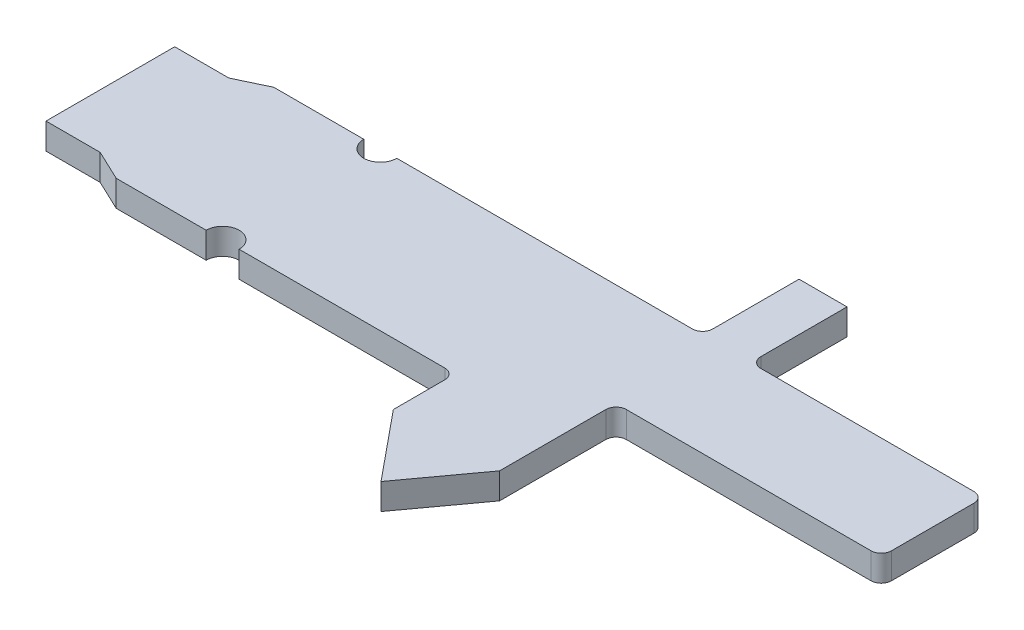
from build123d import *

# Parameters (mm, degrees)
BOSS_EXTRUDE1_DEPTH = 0.9652


with BuildPart() as part:
    # Sketch2 → Boss-Extrude1 (new body)
    with BuildSketch(Plane(origin=(0, 0, 0), x_dir=(1, 0, 0), z_dir=(0, 1, 0))):
        with BuildLine():
            Line((14.732, -0.508), (14.732, 2.54))
            ThreePointArc((14.732, 2.54), (14.620407684, 2.809407684), (14.351, 2.921))
            Line((14.351, 2.921), (6.458532376, 2.921))
            ThreePointArc((6.458532376, 2.921), (6.189124692, 3.032592316), (6.077532376, 3.302))
            Line((6.077532376, 3.302), (6.077532376, 6.495707179))
            Line((6.077532376, 6.495707179), (4.299532376, 6.495707179))
            Line((4.299532376, 6.495707179), (4.299532376, 3.302))
            ThreePointArc((4.299532376, 3.302), (4.187940059, 3.032592316), (3.918532376, 2.921))
            Line((3.918532376, 2.921), (0.5842, 2.921))
            Line((0.5842, 2.921), (-7.0358, 2.921))
            ThreePointArc((-7.0358, 2.921), (-7.647331795, 2.309468205), (-8.258863591, 2.921))
            Line((-8.258863591, 2.921), (-11.594310971, 2.921))
            Line((-11.594310971, 2.921), (-12.723617207, 2.385330376))
            Line((-12.723617207, 2.385330376), (-14.732, 2.385330376))
            Line((-14.732, 2.385330376), (-14.732, -2.385330376))
            Line((-14.732, -2.385330376), (-12.723617207, -2.385330376))
            Line((-12.723617207, -2.385330376), (-11.594310971, -2.921))
            Line((-11.594310971, -2.921), (-8.258863591, -2.921))
            ThreePointArc((-8.258863591, -2.921), (-7.647331795, -2.309468205), (-7.0358, -2.921))
            Line((-7.0358, -2.921), (0.5842, -2.921))
            ThreePointArc((0.5842, -2.921), (0.853607684, -3.032592316), (0.9652, -3.302))
            Line((0.9652, -3.302), (0.9652, -5.207))
            Line((0.9652, -5.207), (3.048, -7.747))
            Line((3.048, -7.747), (4.9022, -5.207))
            Line((4.9022, -5.207), (4.9022, -2.921))
            Line((4.9022, -2.921), (4.9022, -1.27))
            ThreePointArc((4.9022, -1.27), (5.013792316, -1.000592316), (5.2832, -0.889))
            Line((5.2832, -0.889), (14.351, -0.889))
            ThreePointArc((14.351, -0.889), (14.620407684, -0.777407684), (14.732, -0.508))
        make_face()
    extrude(amount=BOSS_EXTRUDE1_DEPTH)


solid = part.part
